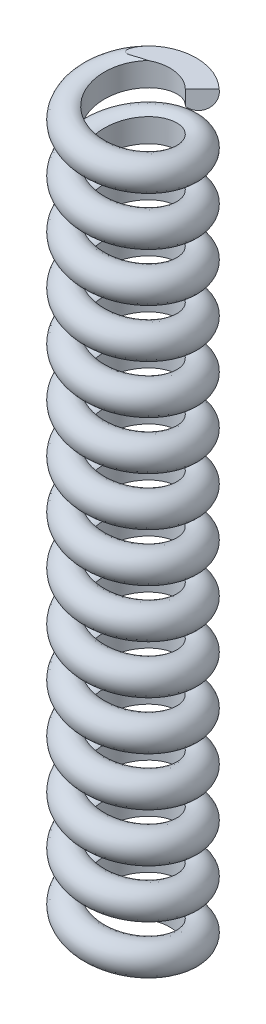
from build123d import *

# Parameters (mm, degrees)
SWEEP1_PITCH            = 4.163934426
SWEEP1_HEIGHT           = 63.5
SWEEP1_RADIUS           = 3.96875
SWEEP1_START_ANGLE      = -135
SWEEP1_PROFILE_R        = 1.27
SKETCH13_R              = 3.175
CENTRALHOLE_DEPTH       = 66.175118045
CENTRALHOLE_DEPTH_BACK  = 66.175118045
SKETCH18_W              = 25.988164438
SKETCH18_H              = 6.348853973
SKETCH18_W_2            = 34.972890229
SKETCH18_H_2            = 10.176817343
CUT_EXTRUDE1_DEPTH      = 66.175118045
CUT_EXTRUDE1_DEPTH_BACK = 66.175118045


with BuildPart() as part:
    # Sweep1: sweep along a helix
    with BuildLine() as sweep1_path:
        add(Helix(SWEEP1_PITCH, SWEEP1_HEIGHT, SWEEP1_RADIUS, center=(0, 0, 0), direction=(0, 1, 0), lefthand=True, mode=Mode.PRIVATE).rotate(Axis((0, 0, 0), (0, 1, 0)), SWEEP1_START_ANGLE))
    # Sweep1 profile (on start of the path) → Sweep1 (sweep)
    with BuildSketch(Plane(origin=(-2.806330038, 0, -2.806330038), x_dir=(-0.7071067811867131, 0, -0.707106781186382), z_dir=(0.6974501087624351, 0.16470182626212607, -0.6974501087627616))):
        Circle(SWEEP1_PROFILE_R)
    sweep(path=sweep1_path.line, is_frenet=True)

    # Sketch13 → CentralHole (cut, two sides)
    with BuildSketch(Plane(origin=(0, 0, 0), x_dir=(1, 0, 0), z_dir=(0, 1, 0))) as centralhole_sk:
        Circle(SKETCH13_R)
    extrude(amount=CENTRALHOLE_DEPTH, mode=Mode.SUBTRACT)
    extrude(centralhole_sk.sketch, amount=-CENTRALHOLE_DEPTH_BACK, mode=Mode.SUBTRACT)

    # Sketch18 → Cut-Extrude1 (cut, two sides)
    with BuildSketch(Plane.XY) as cut_extrude1_sk:
        with Locations((3.584887583, -3.343746512)):
            Rectangle(SKETCH18_W, SKETCH18_H)
        with Locations((2.182267914, 68.757728197)):
            Rectangle(SKETCH18_W_2, SKETCH18_H_2)
    extrude(amount=CUT_EXTRUDE1_DEPTH, mode=Mode.SUBTRACT)
    extrude(cut_extrude1_sk.sketch, amount=-CUT_EXTRUDE1_DEPTH_BACK, mode=Mode.SUBTRACT)


solid = part.part
